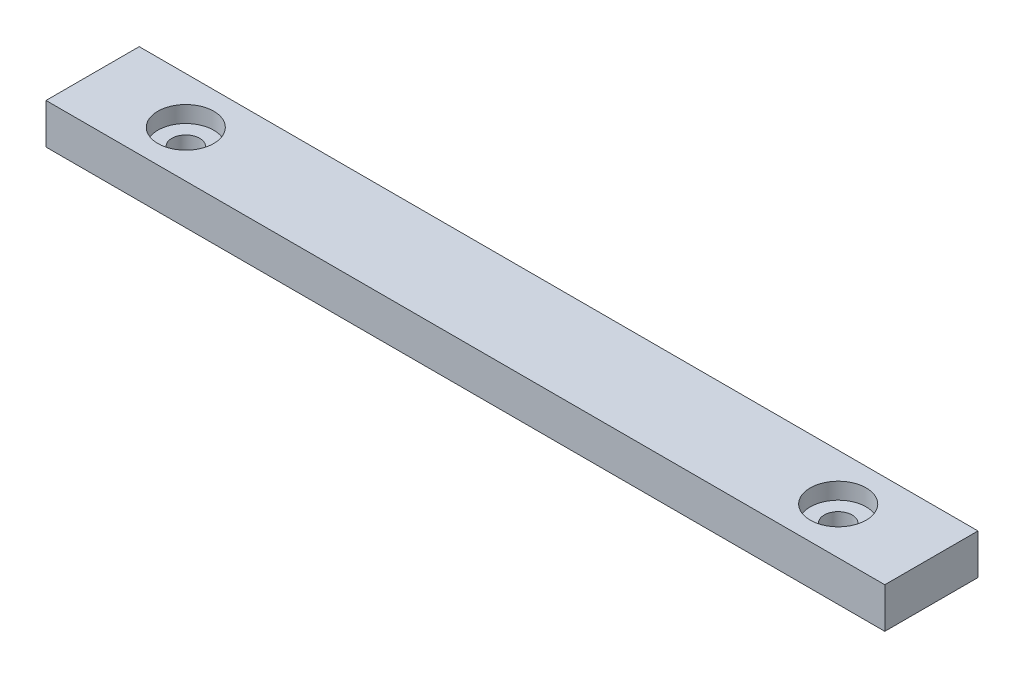
from build123d import *

# Parameters (mm, degrees)
SKETCH1_W                               = 270
SKETCH1_H                               = 30
BOSS_EXTRUDE1_DEPTH                     = 13
CBORE_FOR_M8_HEX_HEAD_BOLT1_D           = 9
CBORE_FOR_M8_HEX_HEAD_BOLT1_DEPTH       = 15
CBORE_FOR_M8_HEX_HEAD_BOLT1_CBORE_D     = 18.011
CBORE_FOR_M8_HEX_HEAD_BOLT1_CBORE_DEPTH = 5.3
CBORE_FOR_M8_HEX_HEAD_BOLT1_TIP         = 2.703872786


with BuildPart() as part:
    # Sketch1 → Boss-Extrude1 (new body)
    with BuildSketch(Plane(origin=(0, 0, 0), x_dir=(1, 0, 0), z_dir=(0, 1, 0))):
        Rectangle(SKETCH1_W, SKETCH1_H)
    extrude(amount=BOSS_EXTRUDE1_DEPTH)

    # CBORE for M8 Hex Head Bolt1
    with Locations(Plane(origin=(-105, 13, 0), x_dir=(0, 0, 1), z_dir=(0, 1, 0))):
        with Locations((0, 0), (0, 210)):
            CounterBoreHole(CBORE_FOR_M8_HEX_HEAD_BOLT1_D / 2, CBORE_FOR_M8_HEX_HEAD_BOLT1_CBORE_D / 2, CBORE_FOR_M8_HEX_HEAD_BOLT1_CBORE_DEPTH, depth=CBORE_FOR_M8_HEX_HEAD_BOLT1_DEPTH)
            with Locations((0, 0, -(CBORE_FOR_M8_HEX_HEAD_BOLT1_DEPTH + CBORE_FOR_M8_HEX_HEAD_BOLT1_TIP / 2))):  # 118° drill point
                Cone(0, CBORE_FOR_M8_HEX_HEAD_BOLT1_D / 2, CBORE_FOR_M8_HEX_HEAD_BOLT1_TIP, mode=Mode.SUBTRACT)


solid = part.part
